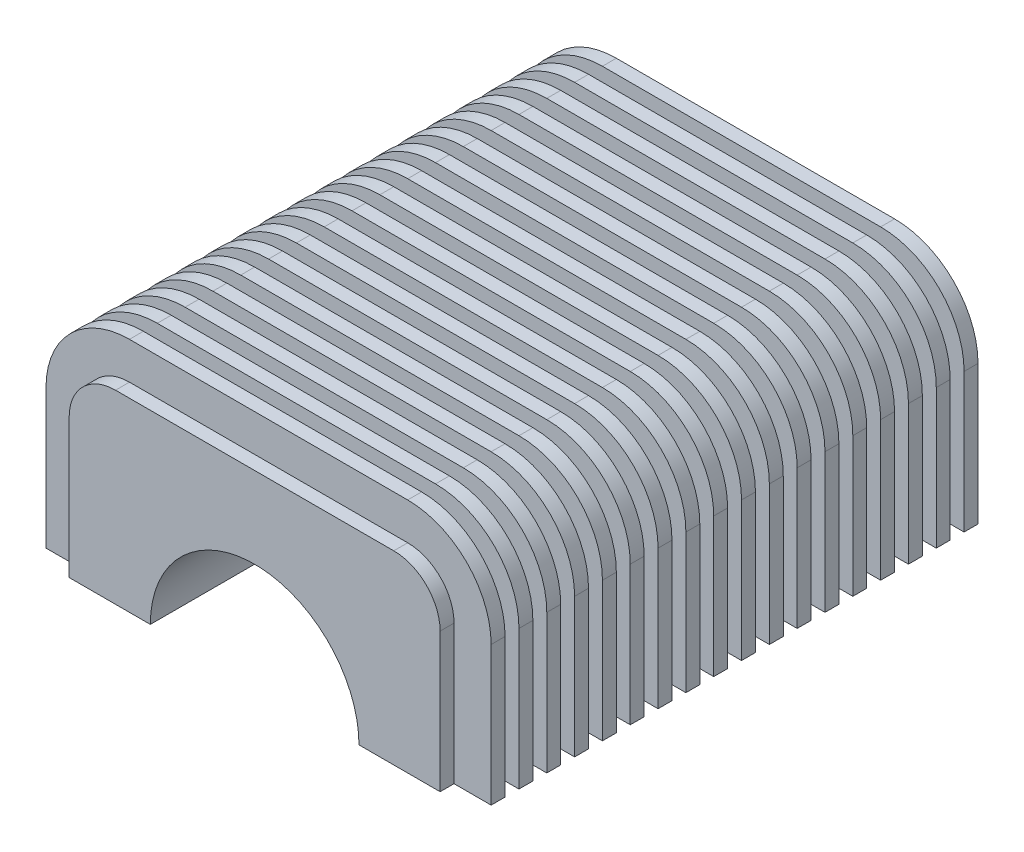
from build123d import *

# Parameters (mm, degrees)
DODANIE_WYCI_GNI_CIE1_DEPTH = 108
ZAOKR_GLENIE1_R             = 10
DODANIE_WYCI_GNI_CIE2_DEPTH = 3
SZYK_LINIOWY1_COUNT         = 18
SZYK_LINIOWY1_PITCH         = 6


with BuildPart() as part:
    # Szkic1 → Dodanie-wyciągnięcie1 (new body)
    with BuildSketch(Plane.XY):
        with BuildLine():
            Line((22.5, 0), (40, 0))
            Line((40, 0), (40, 40))
            Line((40, 40), (-40, 40))
            Line((-40, 40), (-40, 0))
            Line((-40, 0), (-22.5, 0))
            ThreePointArc((-22.5, 0), (0, 22.5), (22.5, 0))
        make_face()
    extrude(amount=DODANIE_WYCI_GNI_CIE1_DEPTH)

    # Zaokrąglenie1
    zaokr_glenie1_edges = [part.edges().sort_by_distance(p)[0] for p in [
        (-40, 40, 54),
        (40, 40, 54),
    ]]
    fillet(zaokr_glenie1_edges, radius=ZAOKR_GLENIE1_R)

    # Szkic2 → Dodanie-wyciągnięcie2 (add)
    with BuildSketch(Plane.XY):
        with BuildLine():
            Line((30, 48), (-30, 48))
            ThreePointArc((-30, 48), (-42.727922061, 42.727922061), (-48, 30))
            Line((-48, 30), (-48, 0))
            Line((-48, 0), (-40, 0))
            Line((-40, 0), (-40, 30))
            ThreePointArc((-40, 30), (-37.071067812, 37.071067812), (-30, 40))
            Line((-30, 40), (30, 40))
            ThreePointArc((30, 40), (37.071067812, 37.071067812), (40, 30))
            Line((40, 30), (40, 0))
            Line((40, 0), (48, 0))
            Line((48, 0), (48, 30))
            ThreePointArc((48, 30), (42.727922061, 42.727922061), (30, 48))
        make_face()
    dodanie_wyci_gni_cie2 = extrude(amount=DODANIE_WYCI_GNI_CIE2_DEPTH)

    # Szyk liniowy1: Dodanie-wyciągnięcie2 ×18
    with Locations(*[(0, 0, i * SZYK_LINIOWY1_PITCH) for i in range(1, SZYK_LINIOWY1_COUNT)]):
        add(dodanie_wyci_gni_cie2)


solid = part.part
